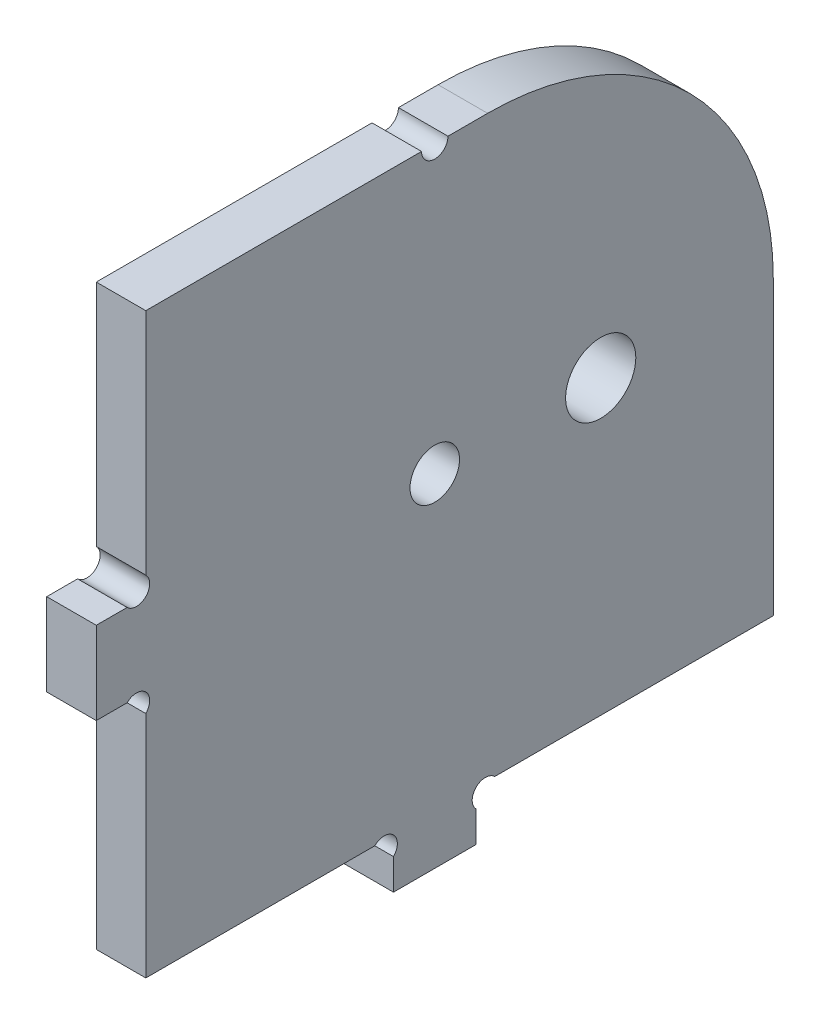
from build123d import *

# Parameters (mm, degrees)
ESQUISSE1_R        = 3
ESQUISSE1_R_2      = 4.25
BOSS_EXTRU_1_DEPTH = 6


with BuildPart() as part:
    # Esquisse1 → Boss.-Extru.1 (new body)
    with BuildSketch(Plane(origin=(0, 0, 0), x_dir=(0, 0, -1), z_dir=(1, 0, 0))):
        with BuildLine():
            Line((46, 3.7372583), (46, 0))
            Line((46, 0), (36, 0))
            Line((36, 0), (36, 3.7372583))
            ThreePointArc((36, 3.7372583), (36, 6), (33.7372583, 6))
            Line((33.7372583, 6), (6, 6))
            Line((6, 6), (6, 33.7372583))
            ThreePointArc((6, 33.7372583), (6, 36), (3.7372583, 36))
            Line((3.7372583, 36), (0, 36))
            Line((0, 36), (0, 46))
            Line((0, 46), (3.7372583, 46))
            ThreePointArc((3.7372583, 46), (6, 46), (6, 48.2627417))
            Line((6, 48.2627417), (6, 76))
            Line((6, 76), (39.4, 76))
            ThreePointArc((39.4, 76), (41, 74.4), (42.6, 76))
            Line((42.6, 76), (47.4, 76))
            ThreePointArc((47.4, 76), (71.865894629, 65.865894629), (82, 41.4))
            Line((82, 41.4), (82, 6))
            Line((82, 6), (48.2627417, 6))
            ThreePointArc((48.2627417, 6), (46, 6), (46, 3.7372583))
        make_face()
        with Locations((41, 41.4)):
            Circle(ESQUISSE1_R, mode=Mode.SUBTRACT)
        with Locations((61.1, 41.4)):
            Circle(ESQUISSE1_R_2, mode=Mode.SUBTRACT)
    extrude(amount=BOSS_EXTRU_1_DEPTH)


solid = part.part
